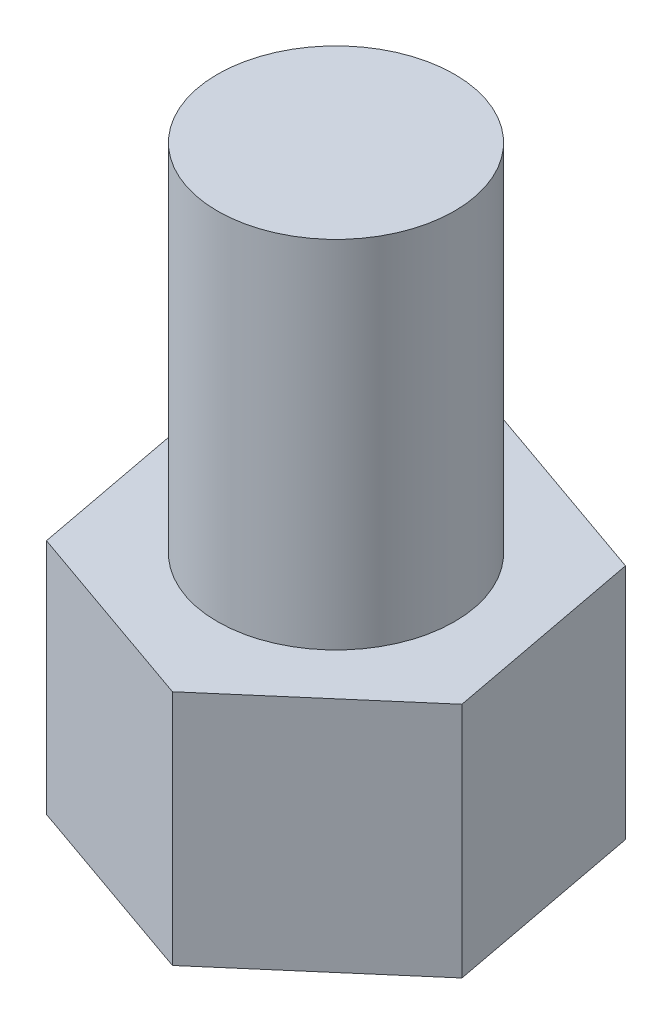
from build123d import *

# Parameters (mm, degrees)
EXTRUDE_1_DEPTH = 2
SKETCH_2_R      = 1
EXTRUDE_2_DEPTH = 3


with BuildPart() as part:
    # 草图1 → 凸台-拉伸1 (new body)
    with BuildSketch(Plane(origin=(0, 0, 0), x_dir=(1, 0, 0), z_dir=(0, 1, 0))):
        Polygon((1.634810628, -0.57218372), (1.312930951, 1.129695675), (-0.321879677, 1.701879395), (-1.634810628, 0.57218372), (-1.312930951, -1.129695675), (0.321879677, -1.701879395), align=None)
    extrude(amount=EXTRUDE_1_DEPTH)

    # 草图2 → 凸台-拉伸2 (add)
    with BuildSketch(Plane(origin=(0, 2, 0), x_dir=(1, 0, 0), z_dir=(0, 1, 0))):
        Circle(SKETCH_2_R)
    extrude(amount=EXTRUDE_2_DEPTH)


solid = part.part
